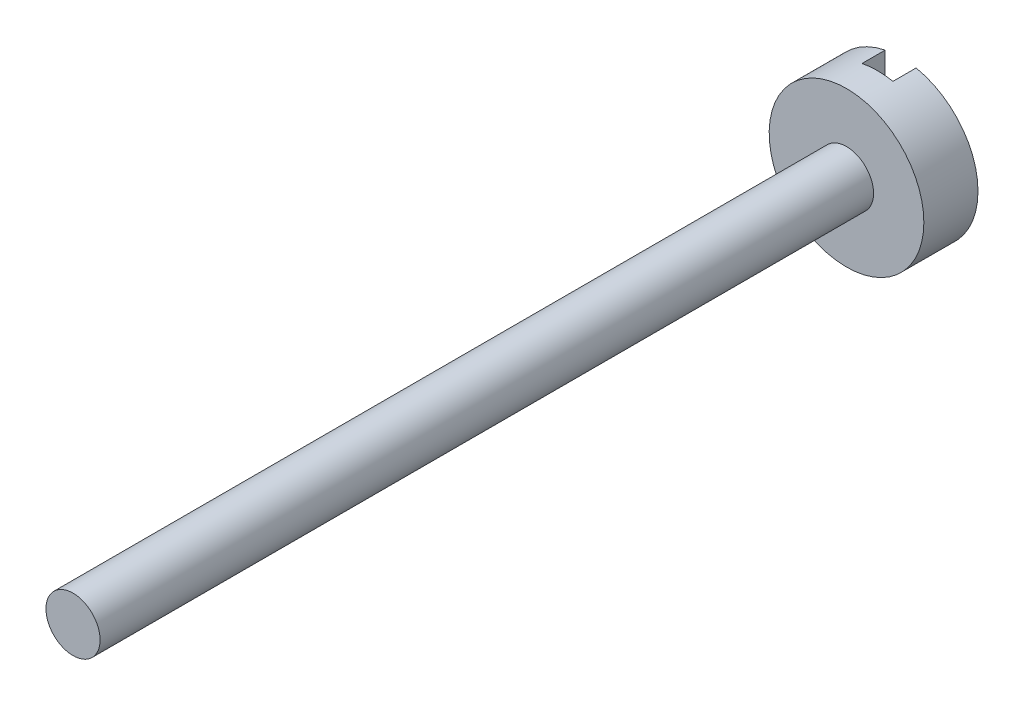
from build123d import *

# Parameters (mm, degrees)
SKETCH1_R           = 1
BOSS_EXTRUDE1_DEPTH = 0.7
SKETCH3_R           = 0.35
BOSS_EXTRUDE2_DEPTH = 10
SKETCH5_W           = 0.4
SKETCH5_H           = 2
CUT_EXTRUDE1_DEPTH  = 0.3


with BuildPart() as part:
    # Sketch1 → Boss-Extrude1 (new body)
    with BuildSketch(Plane.XY):
        Circle(SKETCH1_R)
    extrude(amount=BOSS_EXTRUDE1_DEPTH)

    # Sketch3 → Boss-Extrude2 (add)
    with BuildSketch(Plane.XY.offset(0.7)):
        Circle(SKETCH3_R)
    extrude(amount=BOSS_EXTRUDE2_DEPTH)

    # Sketch5 → Cut-Extrude1 (cut)
    with BuildSketch(Plane(origin=(0, 0, 0), x_dir=(-1, 0, 0), z_dir=(0, 0, -1))):
        Rectangle(SKETCH5_W, SKETCH5_H)
    extrude(amount=-CUT_EXTRUDE1_DEPTH, mode=Mode.SUBTRACT)


solid = part.part
